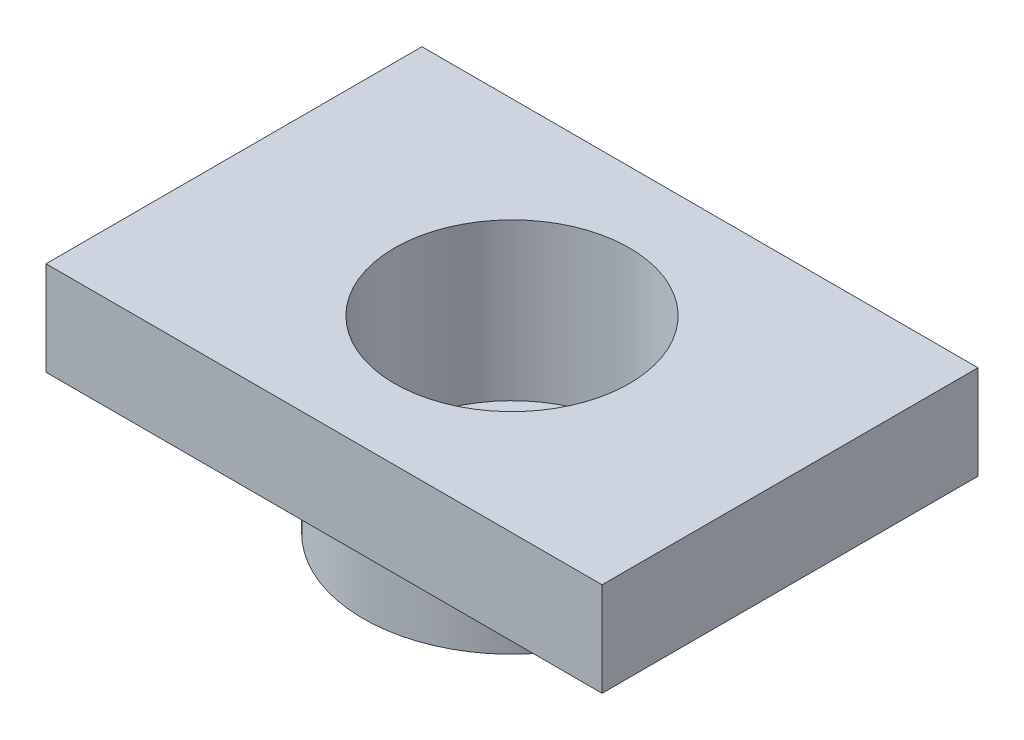
from build123d import *

# Parameters (mm, degrees)
ESQUISSE4_R           = 1.5
EXTRUSION3_DEPTH      = 25
ESQUISSE5_OUTSIDE_W   = 153.718
ESQUISSE5_OUTSIDE_H   = 153.718
ESQUISSE5_OUTSIDE_W_2 = 71
ESQUISSE5_OUTSIDE_H_2 = 48
EXTRUSION4_DEPTH      = 13


with BuildPart() as part:
    # Esquisse1 → Révolution1 (revolve)
    with BuildSketch(Plane.XY):
        Polygon((19, -12), (59, -12), (59, 0), (15, 0), (15, -20), (9, -20), (9, -24), (19, -24), align=None)
    revolve(axis=Axis((0, 0, 0), (0, -1, 0)))

    # Esquisse4 → Extrusion3 (cut, through all)
    with BuildSketch(Plane.XZ.offset(24)):
        with Locations((0, 13)):
            Circle(ESQUISSE4_R)
        with Locations((13, 0)):
            Circle(ESQUISSE4_R)
        with Locations((0, -13)):
            Circle(ESQUISSE4_R)
        with Locations((-13, 0)):
            Circle(ESQUISSE4_R)
    extrude(amount=-EXTRUSION3_DEPTH, mode=Mode.SUBTRACT)

    # Esquisse5 outside → Extrusion4 (cut, through all)
    with BuildSketch(Plane.XZ.offset(12)):
        Rectangle(ESQUISSE5_OUTSIDE_W, ESQUISSE5_OUTSIDE_H)
        Rectangle(ESQUISSE5_OUTSIDE_W_2, ESQUISSE5_OUTSIDE_H_2, mode=Mode.SUBTRACT)
    extrude(amount=-EXTRUSION4_DEPTH, mode=Mode.SUBTRACT)


solid = part.part
